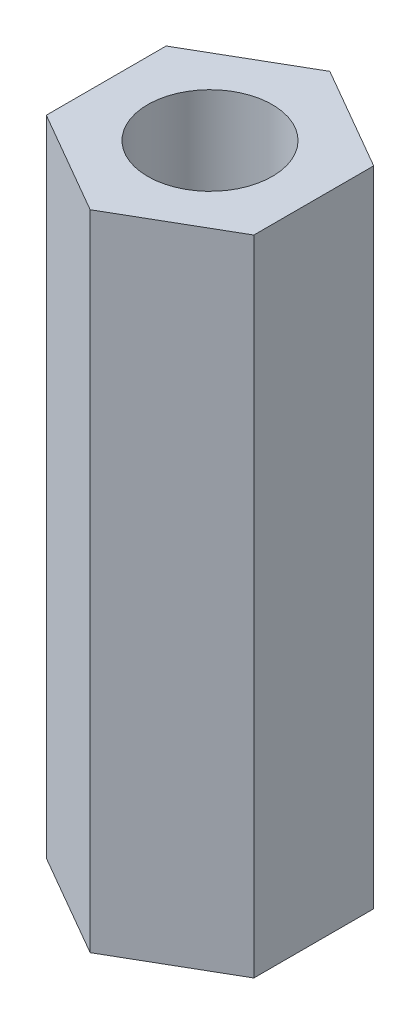
from build123d import *

# Parameters (mm, degrees)
SKETCH_1_R      = 1.5
EXTRUDE_1_DEPTH = 15.5


with BuildPart() as part:
    # 草圖1 → 填料-伸長1 (new body)
    with BuildSketch(Plane(origin=(0, 0, 0), x_dir=(1, 0, 0), z_dir=(0, 1, 0))):
        Polygon((0, 2.886751346), (-2.5, 1.443375673), (-2.5, -1.443375673), (0, -2.886751346), (2.5, -1.443375673), (2.5, 1.443375673), align=None)
        Circle(SKETCH_1_R, mode=Mode.SUBTRACT)
    extrude(amount=EXTRUDE_1_DEPTH)


solid = part.part
